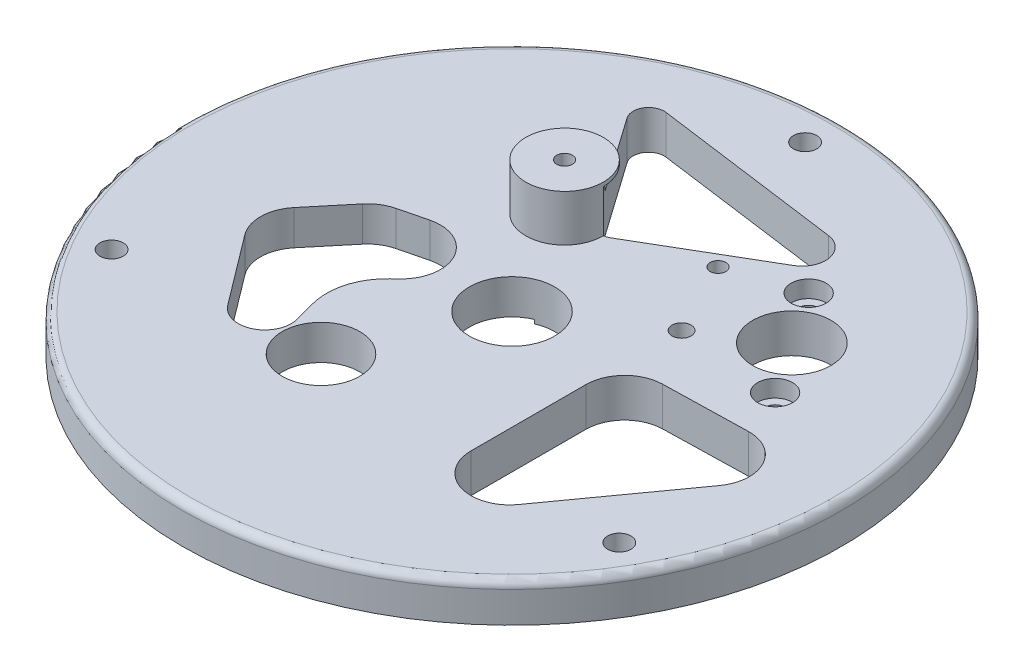
from build123d import *

# Parameters (mm, degrees)
SKETCH1_R                = 42.5
SKETCH1_R_2              = 5
BOSS_EXTRUDE1_DEPTH      = 5
SKETCH2_R                = 1.2
SKETCH2_R_2              = 1.225
SKETCH2_R_3              = 5.05
SKETCH2_R_4              = 1.015
CUT_EXTRUDE1_DEPTH       = 10
SKETCH5_R                = 5
SKETCH5_R_2              = 1.015
BOSS_EXTRUDE2_DEPTH      = 6
SKETCH9_R                = 2.357259082
BOSS_EXTRUDE4_DEPTH      = 1
FILLET1_R                = 1
SKETCH10_R               = 1.5
CUT_EXTRUDE3_DEPTH       = 2.2
CUT_EXTRUDE3_DEPTH_BACK  = 16
CUT_EXTRUDE6_DEPTH       = 0.5
CUT_EXTRUDE7_DEPTH       = 10
CUT_EXTRUDE8_DEPTH       = 10
CUT_EXTRUDE8_DEPTH_BACK  = 10
CUT_EXTRUDE9_DEPTH       = 10
CUT_EXTRUDE9_DEPTH_BACK  = 10
SKETCH17_R               = 5.5
CUT_EXTRUDE10_DEPTH      = 10
CUT_EXTRUDE10_DEPTH_BACK = 10
SKETCH18_R               = 2.25
CUT_EXTRUDE11_DEPTH      = 2.2


with BuildPart() as part:
    # Sketch1 → Boss-Extrude1 (new body)
    with BuildSketch(Plane(origin=(0, 0, 0), x_dir=(1, 0, 0), z_dir=(0, 1, 0))):
        Circle(SKETCH1_R)
        with Locations((-7.573934673, -17.06033615)):
            Circle(SKETCH1_R_2, mode=Mode.SUBTRACT)
    extrude(amount=BOSS_EXTRUDE1_DEPTH)

    # Sketch2 → Cut-Extrude1 (cut)
    with BuildSketch(Plane(origin=(0, 5, 0), x_dir=(1, 0, 0), z_dir=(0, 1, 0))):
        with Locations((26.030814012, 7.899159566)):
            Circle(SKETCH2_R)
        with Locations((17.087578103, 21.16635714)):
            Circle(SKETCH2_R)
        with Locations((13.062426036, 8.805202225)):
            Circle(SKETCH2_R_2)
        with Locations((21.559196058, 14.532758353)):
            Circle(SKETCH2_R_3)
        with Locations((8.320757608, 18.248434254)):
            Circle(SKETCH2_R_4)
    extrude(amount=-CUT_EXTRUDE1_DEPTH, mode=Mode.SUBTRACT)

    # Sketch5 → Boss-Extrude2 (add)
    with BuildSketch(Plane(origin=(0, 5, 0), x_dir=(1, 0, 0), z_dir=(0, 1, 0))):
        with Locations((-7.55311225, 14.331451264)):
            Circle(SKETCH5_R)
        with Locations((-7.55311225, 14.331451264)):
            Circle(SKETCH5_R_2, mode=Mode.SUBTRACT)
    extrude(amount=BOSS_EXTRUDE2_DEPTH)

    # Sketch9 → Boss-Extrude4 (add)
    with BuildSketch(Plane.XZ):
        with Locations((8.320757608, -18.248434254)):
            Circle(SKETCH9_R)
    extrude(amount=-BOSS_EXTRUDE4_DEPTH)

    # Fillet1
    fillet1_edges = [part.edges().sort_by_distance(p)[0] for p in [
        (-42.5, 5, 0),
    ]]
    fillet(fillet1_edges, radius=FILLET1_R)

    # Sketch10 → Cut-Extrude3 (cut, two sides)
    with BuildSketch(Plane(origin=(0, 5, 0), x_dir=(1, 0, 0), z_dir=(0, 1, 0))) as cut_extrude3_sk:
        with Locations((0, 37.8)):
            Circle(SKETCH10_R)
        with Locations((-32.735760263, -18.9)):
            Circle(SKETCH10_R)
        with Locations((32.735760263, -18.9)):
            Circle(SKETCH10_R)
    extrude(amount=CUT_EXTRUDE3_DEPTH, mode=Mode.SUBTRACT)
    extrude(cut_extrude3_sk.sketch, amount=-CUT_EXTRUDE3_DEPTH_BACK, mode=Mode.SUBTRACT)

    # Sketch12 → Cut-Extrude6 (cut)
    with BuildSketch(Plane.XZ):
        with BuildLine():
            Line((-21.313834783, 24.76213107), (-34.538834783, 1.855759139))
            ThreePointArc((-34.538834783, 1.855759139), (-35.038336896, -1.938336086), (-32.708707764, -4.974367879))
            Line((-32.708707764, -4.974367879), (-14.089161583, -15.724367879))
            ThreePointArc((-14.089161583, -15.724367879), (-10.295066357, -16.223869992), (-7.259034564, -13.894240861))
            Line((-7.259034564, -13.894240861), (5.965965436, 9.01213107))
            ThreePointArc((5.965965436, 9.01213107), (0.201065327, 30.527031179), (-21.313834783, 24.76213107))
        make_face()
    extrude(amount=-CUT_EXTRUDE6_DEPTH, mode=Mode.SUBTRACT)

    # Sketch13 → Cut-Extrude7 (cut)
    with BuildSketch(Plane(origin=(0, 5, 0), x_dir=(1, 0, 0), z_dir=(0, 1, 0))):
        with BuildLine():
            Line((32.816836472, -6.07169605), (21.984996749, -21.138640776))
            ThreePointArc((21.984996749, -21.138640776), (16.391033491, -22.978825985), (12.925236211, -18.21784334))
            Line((12.925236211, -18.21784334), (12.931687147, -3.407234286))
            ThreePointArc((12.931687147, -3.407234286), (14.35531099, 0.084802692), (17.813324255, 1.589186743))
            Line((17.813324255, 1.589186743), (28.638713042, 1.845522414))
            ThreePointArc((28.638713042, 1.845522414), (33.179093412, -0.819461796), (32.816836472, -6.07169605))
        make_face()
    extrude(amount=-CUT_EXTRUDE7_DEPTH, mode=Mode.SUBTRACT)

    # Sketch15 → Cut-Extrude8 (cut, two sides)
    with BuildSketch(Plane.XZ.offset(-0.5)) as cut_extrude8_sk:
        with BuildLine():
            Line((-4.454061063, -15.186961023), (-14.190064184, -29.028285448))
            ThreePointArc((-14.190064184, -29.028285448), (-14.263329759, -31.217660805), (-12.286203391, -32.160901823))
            Line((-12.286203391, -32.160901823), (11.926297184, -28.886712635))
            ThreePointArc((11.926297184, -28.886712635), (14.476623444, -26.492368994), (13.043930349, -23.301062679))
            Line((13.043930349, -23.301062679), (-1.808225202, -14.611372289))
            ThreePointArc((-1.808225202, -14.611372289), (-3.243361659, -14.383326468), (-4.454061063, -15.186961023))
        make_face()
    extrude(amount=CUT_EXTRUDE8_DEPTH, mode=Mode.SUBTRACT)
    extrude(cut_extrude8_sk.sketch, amount=-CUT_EXTRUDE8_DEPTH_BACK, mode=Mode.SUBTRACT)

    # Sketch16 → Cut-Extrude9 (cut, two sides)
    with BuildSketch(Plane.XZ.offset(-0.5)) as cut_extrude9_sk:
        with BuildLine():
            Line((-12.984156175, 14.705600426), (-13.719701132, 11.95882482))
            ThreePointArc((-13.719701132, 11.95882482), (-13.693758532, 7.802544191), (-11.54963643, 4.241914739))
            Line((-11.54963643, 4.241914739), (-10.842839117, 3.568938111))
            ThreePointArc((-10.842839117, 3.568938111), (-9.907482144, -2.457917187), (-15.493944375, -4.905225341))
            Line((-15.493944375, -4.905225341), (-19.004093622, -4.034917019))
            ThreePointArc((-19.004093622, -4.034917019), (-20.457115896, -3.417911536), (-21.645362284, -2.3786618))
            Line((-21.645362284, -2.3786618), (-25.653320737, 2.441392154))
            ThreePointArc((-25.653320737, 2.441392154), (-26.807383132, 5.519886283), (-25.80025353, 8.649531003))
            Line((-25.80025353, 8.649531003), (-19.012059198, 17.647148968))
            ThreePointArc((-19.012059198, 17.647148968), (-14.786139745, 18.659973084), (-12.984156175, 14.705600426))
        make_face()
    extrude(amount=CUT_EXTRUDE9_DEPTH, mode=Mode.SUBTRACT)
    extrude(cut_extrude9_sk.sketch, amount=-CUT_EXTRUDE9_DEPTH_BACK, mode=Mode.SUBTRACT)

    # Sketch17 → Cut-Extrude10 (cut, two sides)
    with BuildSketch(Plane.XZ.offset(-0.5)) as cut_extrude10_sk:
        Circle(SKETCH17_R)
    extrude(amount=CUT_EXTRUDE10_DEPTH, mode=Mode.SUBTRACT)
    extrude(cut_extrude10_sk.sketch, amount=-CUT_EXTRUDE10_DEPTH_BACK, mode=Mode.SUBTRACT)

    # Sketch18 → Cut-Extrude11 (cut)
    with BuildSketch(Plane(origin=(0, 5, 0), x_dir=(1, 0, 0), z_dir=(0, 1, 0))):
        with Locations((17.087578103, 21.16635714)):
            Circle(SKETCH18_R)
        with Locations((26.030814012, 7.899159566)):
            Circle(SKETCH18_R)
    extrude(amount=-CUT_EXTRUDE11_DEPTH, mode=Mode.SUBTRACT)


solid = part.part
